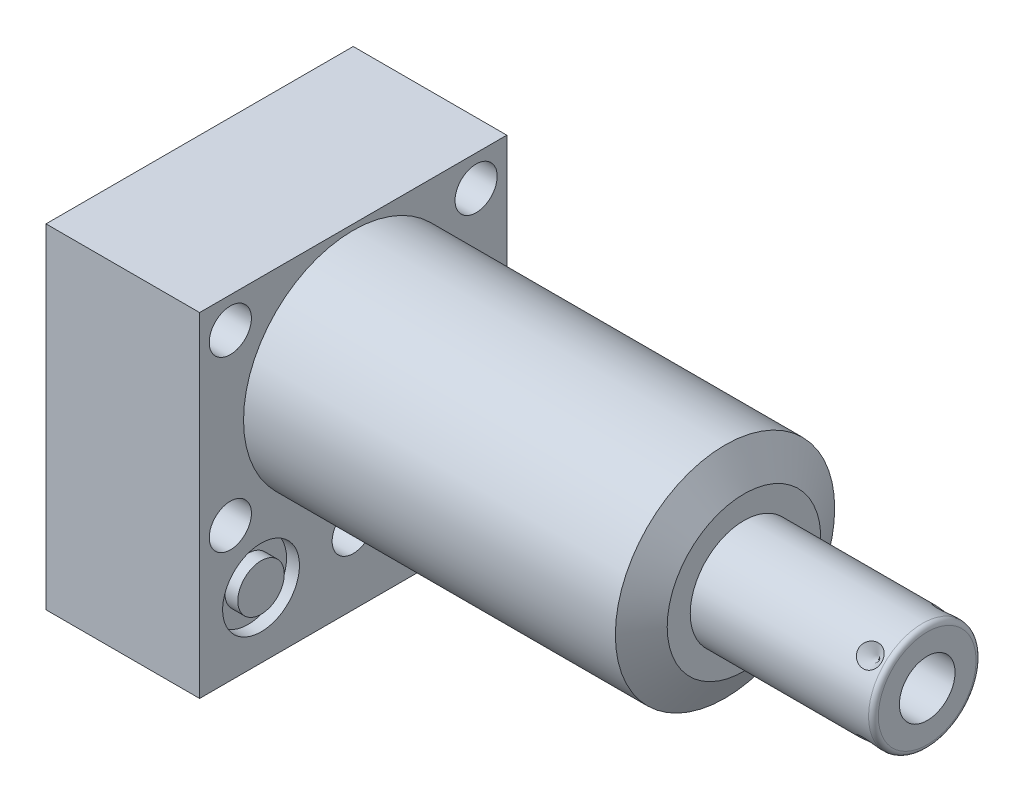
from build123d import *

# Parameters (mm, degrees)
SKETCH1_W           = 63.5
SKETCH1_H           = 69.088
EXTRUDE1_DEPTH      = 80.772
EXTRUDE1_DEPTH_BACK = 31.75
CUT_EXTRUDE1_REACH  = 82.772
SKETCH2_W           = 63.5
SKETCH2_H           = 69.088
SKETCH2_R           = 22.6695
SKETCH18_R          = 7.9375
CUT_EXTRUDE2_DEPTH  = 2.667
SKETCH19_R          = 7.9375
CUT_EXTRUDE3_DEPTH  = 2.667
SKETCH20_R          = 9.525
CUT_EXTRUDE4_DEPTH  = 0.254
SKETCH12_R          = 6.4389
EXTRUDE2_DEPTH      = 1.651
EXTRUDE3_START      = -31.75
SKETCH13_R          = 4.8006
EXTRUDE3_DEPTH      = 31.75
SKETCH14_R          = 1.7653
SKETCH15_R          = 1.7653
CIRPATTERN1_COUNT   = 4
SKETCH21_W          = 4.3561
SKETCH21_H          = 31.75
HOLE1_AT_2_COUNT    = 2
HOLE1_AT_2_PITCH    = 54.58107178
HOLE1_AT_3_COUNT    = 2
HOLE1_AT_3_PITCH    = 34.9504
HOLE1_AT_4_COUNT    = 2
HOLE1_AT_4_PITCH    = 50.8
HOLE1_AT_5_COUNT    = 2
HOLE1_AT_5_PITCH    = 61.661742273


with BuildPart() as part:
    # Sketch1 → Extrude1 (new body, two sides)
    with BuildSketch(Plane(origin=(0, 0, 0), x_dir=(0, 0, -1), z_dir=(1, 0, 0))) as extrude1_sk:
        with Locations((0, -10.7188)):
            Rectangle(SKETCH1_W, SKETCH1_H)
    extrude(amount=EXTRUDE1_DEPTH)
    extrude(extrude1_sk.sketch, amount=-EXTRUDE1_DEPTH_BACK)

    # Sketch2 → Cut-Extrude1 (cut, up to next)
    with BuildSketch(Plane(origin=(0, 0, 0), x_dir=(0, 0, -1), z_dir=(1, 0, 0)), mode=Mode.PRIVATE) as cut_extrude1_sk1:
        with Locations((0, -10.7188)):
            Rectangle(SKETCH2_W, SKETCH2_H)
        Circle(SKETCH2_R, mode=Mode.SUBTRACT)
    cut_extrude1_tool1 = extrude(cut_extrude1_sk1.sketch, amount=CUT_EXTRUDE1_REACH, mode=Mode.PRIVATE) & part.part
    add(cut_extrude1_tool1.solids().sort_by_distance((0, 22.886829, 0))[0], mode=Mode.SUBTRACT)

    # Sketch3 → Cut-Revolve1 (revolve, cut)
    with BuildSketch(Plane.XY, mode=Mode.PRIVATE) as cut_revolve1_sk:
        Polygon((76.849193596, 22.6695), (80.772, 15.875), (80.772, 22.6695), align=None)
    revolve(cut_revolve1_sk.sketch.rotate(Axis((76.037136009, 0, 0), (1, 0, 0)), 90), axis=Axis((76.037136009, 0, 0), (1, 0, 0)), mode=Mode.SUBTRACT)  # turned: the seam where the file's is

    # S2D0002 → Cut-Revolve2 (revolve, cut)
    with BuildSketch(Plane(origin=(-29.083, -31.75, 19.05), x_dir=(0, 1, 0), z_dir=(0, 0, 1)), mode=Mode.PRIVATE) as cut_revolve2_sk:
        Polygon((0, 0), (4.5466, 0), (4.106586662, -2.0701), (3.4544, -2.722286662), (3.4544, -13.97), (0, -13.97), align=None)
    revolve(cut_revolve2_sk.sketch.rotate(Axis((-14.4145, -31.75, 19.05), (-1, 0, 0)), 90), axis=Axis((-14.4145, -31.75, 19.05), (-1, 0, 0)), mode=Mode.SUBTRACT)  # turned: the seam where the file's is

    # Sketch5 → Cut-Revolve3 (revolve, cut)
    with BuildSketch(Plane(origin=(-29.083, -31.75, -19.05), x_dir=(0, 1, 0), z_dir=(0, 0, 1)), mode=Mode.PRIVATE) as cut_revolve3_sk:
        Polygon((0, 0), (4.5466, 0), (4.106586662, -2.0701), (3.4544, -2.722286662), (3.4544, -13.97), (0, -13.97), align=None)
    revolve(cut_revolve3_sk.sketch.rotate(Axis((-14.4145, -31.75, -19.05), (-1, 0, 0)), 90), axis=Axis((-14.4145, -31.75, -19.05), (-1, 0, 0)), mode=Mode.SUBTRACT)  # turned: the seam where the file's is

    # Sketch6 → Cut-Revolve4 (revolve, cut)
    with BuildSketch(Plane(origin=(-2.667, -31.75, 19.05), x_dir=(0, -1, 0), z_dir=(0, 0, 1)), mode=Mode.PRIVATE) as cut_revolve4_sk:
        Polygon((0, 0), (4.5466, 0), (4.106586662, -2.0701), (3.4544, -2.722286662), (3.4544, -12.192), (0, -12.192), align=None)
    revolve(cut_revolve4_sk.sketch.rotate(Axis((-15.4686, -31.75, 19.05), (1, 0, 0)), 90), axis=Axis((-15.4686, -31.75, 19.05), (1, 0, 0)), mode=Mode.SUBTRACT)  # turned: the seam where the file's is

    # Sketch7 → Cut-Revolve5 (revolve, cut)
    with BuildSketch(Plane(origin=(-2.667, -31.75, -19.05), x_dir=(0, -1, 0), z_dir=(0, 0, 1)), mode=Mode.PRIVATE) as cut_revolve5_sk:
        Polygon((0, 0), (4.5466, 0), (4.106586662, -2.0701), (3.4544, -2.722286662), (3.4544, -12.192), (0, -12.192), align=None)
    revolve(cut_revolve5_sk.sketch.rotate(Axis((-15.4686, -31.75, -19.05), (1, 0, 0)), 90), axis=Axis((-15.4686, -31.75, -19.05), (1, 0, 0)), mode=Mode.SUBTRACT)  # turned: the seam where the file's is

    # Sketch8 → Cut-Revolve6 (revolve, cut)
    with BuildSketch(Plane(origin=(-15.875, -51.6128, 19.05), x_dir=(-1, 0, 0), z_dir=(0, 0, 1)), mode=Mode.PRIVATE) as cut_revolve6_sk:
        Polygon((0, -6.604), (6.1849, -6.604), (5.642306865, -9.1567), (4.9784, -9.820606865), (4.9784, -25.654), (0, -25.654), align=None)
    revolve(cut_revolve6_sk.sketch.rotate(Axis((-15.875, -24.9428, 19.05), (0, -1, 0)), 270), axis=Axis((-15.875, -24.9428, 19.05), (0, -1, 0)), mode=Mode.SUBTRACT)  # turned: the seam where the file's is

    # Sketch9 → Cut-Revolve7 (revolve, cut)
    with BuildSketch(Plane(origin=(-15.875, -51.6128, -19.05), x_dir=(-1, 0, 0), z_dir=(0, 0, 1)), mode=Mode.PRIVATE) as cut_revolve7_sk:
        Polygon((0, -6.604), (6.1849, -6.604), (5.642306865, -9.1567), (4.9784, -9.820606865), (4.9784, -25.654), (0, -25.654), align=None)
    revolve(cut_revolve7_sk.sketch.rotate(Axis((-15.875, -24.9428, -19.05), (0, -1, 0)), 270), axis=Axis((-15.875, -24.9428, -19.05), (0, -1, 0)), mode=Mode.SUBTRACT)  # turned: the seam where the file's is

    # Sketch18 → Cut-Extrude2 (cut)
    with BuildSketch(Plane(origin=(0, 0, 0), x_dir=(0, 0, -1), z_dir=(1, 0, 0))):
        with Locations((-19.05, -31.75)):
            Circle(SKETCH18_R)
        with Locations((19.05, -31.75)):
            Circle(SKETCH18_R)
    extrude(amount=-CUT_EXTRUDE2_DEPTH, mode=Mode.SUBTRACT)

    # Sketch19 → Cut-Extrude3 (cut)
    with BuildSketch(Plane.ZY.offset(31.75)):
        with Locations(Location((-19.05, -31.75, 0), (0, 0, 180))):  # turned: the seam where the file's is
            Circle(SKETCH19_R)
        with Locations(Location((19.05, -31.75, 0), (0, 0, 180))):  # turned: the seam where the file's is
            Circle(SKETCH19_R)
    extrude(amount=-CUT_EXTRUDE3_DEPTH, mode=Mode.SUBTRACT)

    # Sketch20 → Cut-Extrude4 (cut)
    with BuildSketch(Plane.XZ.offset(45.2628)):
        with Locations(Location((-15.875, -19.05, 0), (0, 0, 270))):  # turned: the seam where the file's is
            Circle(SKETCH20_R)
        with Locations(Location((-15.875, 19.05, 0), (0, 0, 270))):  # turned: the seam where the file's is
            Circle(SKETCH20_R)
    extrude(amount=-CUT_EXTRUDE4_DEPTH, mode=Mode.SUBTRACT)

    # Sketch10 → Revolve1 (revolve)
    with BuildSketch(Plane.XY, mode=Mode.PRIVATE) as revolve1_sk:
        with BuildLine():
            Line((80.772, 0), (80.772, 11.1125))
            Line((80.772, 11.1125), (117.6274, 11.1125))
            ThreePointArc((117.6274, 11.1125), (118.34582049, 10.81492049), (118.6434, 10.0965))
            Line((118.6434, 10.0965), (118.6434, 0))
            Line((118.6434, 0), (80.772, 0))
        make_face()
    revolve(revolve1_sk.sketch.rotate(Axis((58.270820274, 0, 0), (1, 0, 0)), 90), axis=Axis((58.270820274, 0, 0), (1, 0, 0)))  # turned: the seam where the file's is

    # S2D0001 → Cut-Revolve8 (revolve, cut)
    with BuildSketch(Plane(origin=(118.6434, -5.7531, 0), x_dir=(0, -1, 0), z_dir=(0, 0, 1)), mode=Mode.PRIVATE) as cut_revolve8_sk:
        Polygon((0, 0), (0, -17.018), (-5.7531, -20.474811227), (-5.7531, 0), align=None)
    revolve(cut_revolve8_sk.sketch.rotate(Axis((84.296273767, 0, 0), (1, 0, 0)), 270), axis=Axis((84.296273767, 0, 0), (1, 0, 0)), mode=Mode.SUBTRACT)  # turned: the seam where the file's is

    # Sketch12 → Extrude2 (add)
    with BuildSketch(Plane(origin=(-31.75, -45.0088, 0), x_dir=(0, 0, -1), z_dir=(0, -1, 0))):
        with Locations((-19.05, 15.875)):
            Circle(SKETCH12_R)
    extrude(amount=EXTRUDE2_DEPTH)

    # Sketch13 → Extrude3 (add)
    with BuildSketch(Plane(origin=(0, 0, 0), x_dir=(0, 0, -1), z_dir=(1, 0, 0)).offset(EXTRUDE3_START)):
        with Locations((-19.05, -31.75)):
            Circle(SKETCH13_R)
    extrude(amount=EXTRUDE3_DEPTH)

    # Sketch16 → Cut-Revolve9 (revolve, cut)
    with BuildSketch(Plane(origin=(114.681, 7.857724106, -7.857724106), x_dir=(-1, 0, 0), z_dir=(0, -0.707106781, -0.707106781)), mode=Mode.PRIVATE) as cut_revolve9_sk:
        Polygon((0, 0), (2.413, 0), (0, -2.413), align=None)
    cut_revolve9 = revolve(cut_revolve9_sk.sketch.rotate(Axis((114.681, 4.308539393, -4.308539393), (0, 0.707106781, -0.707106781)), 90), axis=Axis((114.681, 4.308539393, -4.308539393), (0, 0.707106781, -0.707106781)), mode=Mode.SUBTRACT)  # turned: the seam where the file's is

    # CirPattern1: Cut-Revolve9 ×4 about axis
    cirpattern1_axis = Axis((0, 0, 0), (-1, 0, 0))
    for i in range(1, CIRPATTERN1_COUNT):
        add(cut_revolve9.rotate(cirpattern1_axis, i * 360 / CIRPATTERN1_COUNT), mode=Mode.SUBTRACT)

    # Sketch21 → Hole1 (revolve, cut)
    with BuildSketch(Plane(origin=(0, 17.4752, 25.4), x_dir=(0, 0, -1), z_dir=(0, 1, 0))):
        with Locations((2.17805, 15.875)):
            Rectangle(SKETCH21_W, SKETCH21_H)
    hole1 = revolve(axis=Axis((-110, 17.4752, 25.4), (1, 0, 0)), mode=Mode.SUBTRACT)

    # Hole1 at 2: Hole1 ×2
    with Locations(*[Vector(0, -0.885120032, -0.465362793) * (i * HOLE1_AT_2_PITCH) for i in range(1, HOLE1_AT_2_COUNT)]):
        add(hole1, mode=Mode.SUBTRACT)

    # Hole1 at 3: Hole1 ×2
    with Locations(*[(0, -i * HOLE1_AT_3_PITCH, 0) for i in range(1, HOLE1_AT_3_COUNT)]):
        add(hole1, mode=Mode.SUBTRACT)

    # Hole1 at 4: Hole1 ×2
    with Locations(*[(0, 0, -i * HOLE1_AT_4_PITCH) for i in range(1, HOLE1_AT_4_COUNT)]):
        add(hole1, mode=Mode.SUBTRACT)

    # Hole1 at 5: Hole1 ×2
    with Locations(*[Vector(0, -0.566808506, -0.823849572) * (i * HOLE1_AT_5_PITCH) for i in range(1, HOLE1_AT_5_COUNT)]):
        add(hole1, mode=Mode.SUBTRACT)


with BuildPart() as body_2:
    # Sketch14 → Revolve2 (revolve)
    with BuildSketch(Plane(origin=(0, -31.75, -19.05), x_dir=(0, 0, -1), z_dir=(0, -1, 0)), mode=Mode.PRIVATE) as revolve2_sk:
        with Locations((6.1722, -0.9017)):
            Circle(SKETCH14_R)
    revolve(revolve2_sk.sketch.rotate(Axis((-2.84353, -31.75, -19.05), (1, 0, 0)), 180), axis=Axis((-2.84353, -31.75, -19.05), (1, 0, 0)))  # turned: the seam where the file's is


with BuildPart() as body_3:
    # Sketch15 → Revolve3 (revolve)
    with BuildSketch(Plane(origin=(0, -31.75, -19.05), x_dir=(0, 0, -1), z_dir=(0, -1, 0)), mode=Mode.PRIVATE) as revolve3_sk:
        with Locations((6.1722, -30.8483)):
            Circle(SKETCH15_R)
    revolve(revolve3_sk.sketch.rotate(Axis((-32.79013, -31.75, -19.05), (1, 0, 0)), 180), axis=Axis((-32.79013, -31.75, -19.05), (1, 0, 0)))  # turned: the seam where the file's is


solid = Compound([part.part, body_2.part, body_3.part])
